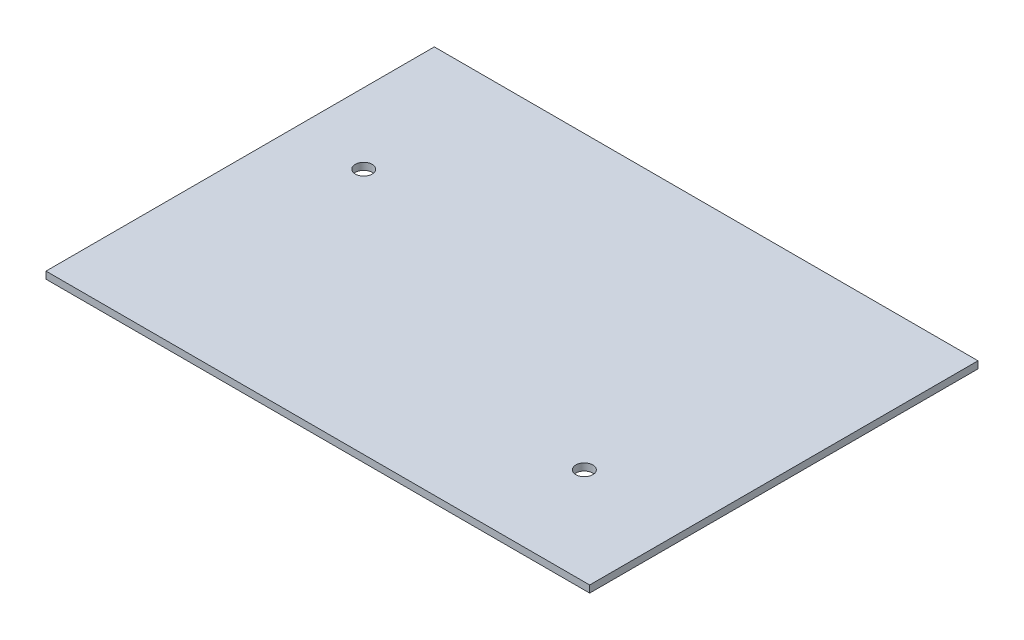
from build123d import *

# Parameters (mm, degrees)
SKETCH1_W                       = 97.79
SKETCH1_H                       = 69.85
EXTRUDE1_DEPTH                  = 1.27
TAP_DRILL_FOR_4_HELICOIL1_D     = 3.048
TAP_DRILL_FOR_4_HELICOIL1_DEPTH = 25.4
TAP_DRILL_FOR_4_HELICOIL1_TIP   = 0.915711583


with BuildPart() as part:
    # Sketch1 → Extrude1 (new body)
    with BuildSketch(Plane(origin=(0, 0, 0), x_dir=(1, 0, 0), z_dir=(0, 1, 0))):
        with Locations((-11.414173127, -11.27370801)):
            Rectangle(SKETCH1_W, SKETCH1_H)
    extrude(amount=EXTRUDE1_DEPTH)

    # Tap Drill for #4 Helicoil1
    with Locations(Plane(origin=(19.065826873, 1.27, 28.73620801), x_dir=(0, 0, 1), z_dir=(0, 1, 0))):
        with Locations((0, 0), (-26.9875, -66.675)):
            Hole(TAP_DRILL_FOR_4_HELICOIL1_D / 2, depth=TAP_DRILL_FOR_4_HELICOIL1_DEPTH)
            with Locations((0, 0, -(TAP_DRILL_FOR_4_HELICOIL1_DEPTH + TAP_DRILL_FOR_4_HELICOIL1_TIP / 2))):  # 118° drill point
                Cone(0, TAP_DRILL_FOR_4_HELICOIL1_D / 2, TAP_DRILL_FOR_4_HELICOIL1_TIP, mode=Mode.SUBTRACT)


solid = part.part
